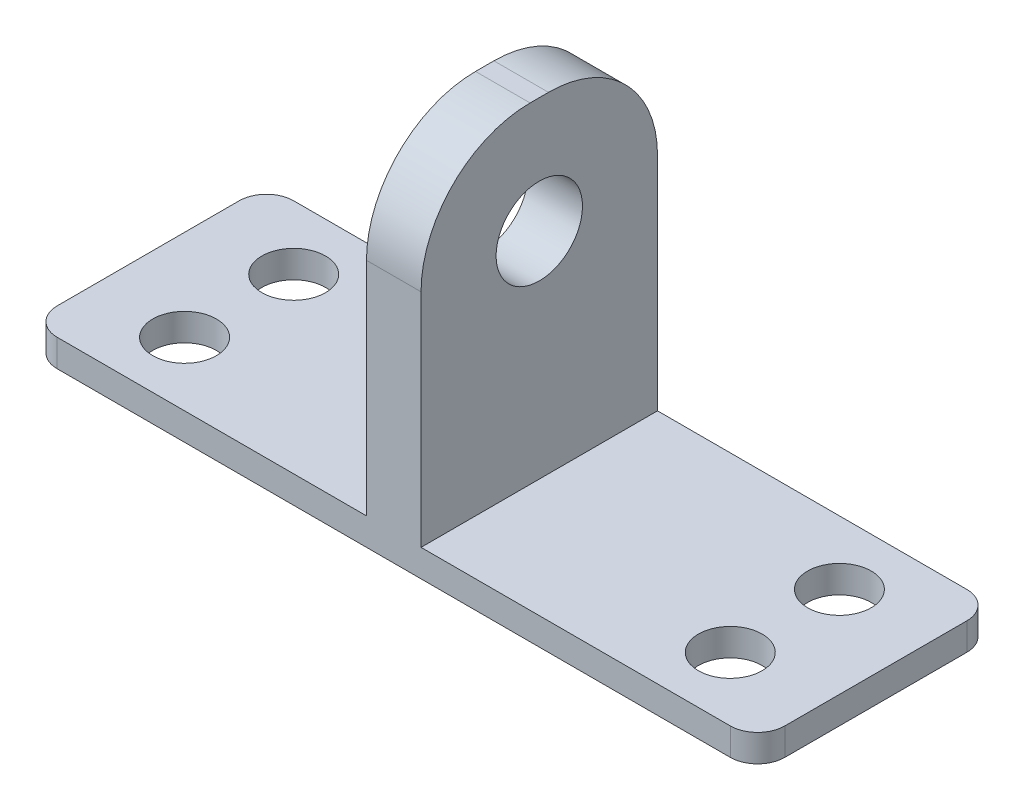
from build123d import *

# Parameters (mm, degrees)
SKETCH1_W           = 80
SKETCH1_H           = 26
SKETCH1_R           = 3.5
BOSS_EXTRUDE1_DEPTH = 3
FILLET1_R           = 2.9972
BOSS_EXTRUDE2_DEPTH = 36.322
FILLET2_R           = 11.9888
CUT_EXTRUDE1_REACH  = 45
SKETCH3_R           = 4.75


with BuildPart() as part:
    # Sketch1 → Boss-Extrude1 (new body)
    with BuildSketch(Plane(origin=(0, 0, 0), x_dir=(1, 0, 0), z_dir=(0, 1, 0))):
        with Locations((40, -13)):
            Rectangle(SKETCH1_W, SKETCH1_H)
        with Locations(Location((10, -19, 0), (0, 0, 270))):  # turned: the seam where the file's is
            Circle(SKETCH1_R, mode=Mode.SUBTRACT)
        with Locations(Location((10, -7, 0), (0, 0, 90))):  # turned: the seam where the file's is
            Circle(SKETCH1_R, mode=Mode.SUBTRACT)
        with Locations(Location((70, -7, 0), (0, 0, 270))):  # turned: the seam where the file's is
            Circle(SKETCH1_R, mode=Mode.SUBTRACT)
        with Locations(Location((70, -19, 0), (0, 0, 90))):  # turned: the seam where the file's is
            Circle(SKETCH1_R, mode=Mode.SUBTRACT)
    extrude(amount=BOSS_EXTRUDE1_DEPTH)

    # Fillet1
    fillet1_edges = [part.edges().sort_by_distance(p)[0] for p in [
        (0, 1.5, 0),
        (80, 1.5, 0),
        (80, 1.5, 26),
        (0, 1.5, 26),
    ]]
    fillet(fillet1_edges, radius=FILLET1_R)

    # Sketch2 → Boss-Extrude2 (add)
    with BuildSketch(Plane(origin=(0, 3, 0), x_dir=(1, 0, 0), z_dir=(0, 1, 0))):
        Polygon((43, 0), (40, 0), (37, 0), (37, -26), (40, -26), (43, -26), align=None)
    extrude(amount=BOSS_EXTRUDE2_DEPTH)

    # Fillet2
    fillet2_edges = [part.edges().sort_by_distance(p)[0] for p in [
        (40, 39.322, 26),
        (40, 39.322, 0),
    ]]
    fillet(fillet2_edges, radius=FILLET2_R)

    # Sketch3 → Cut-Extrude1 (cut, up to next)
    with BuildSketch(Plane.ZY.offset(-37), mode=Mode.PRIVATE) as cut_extrude1_sk1:
        with Locations((13, 26.622)):
            Circle(SKETCH3_R)
    cut_extrude1_tool1 = extrude(cut_extrude1_sk1.sketch, amount=-CUT_EXTRUDE1_REACH, mode=Mode.PRIVATE) & part.part
    add(cut_extrude1_tool1.solids().sort_by_distance((37, 26.622, 13))[0], mode=Mode.SUBTRACT)


solid = part.part
